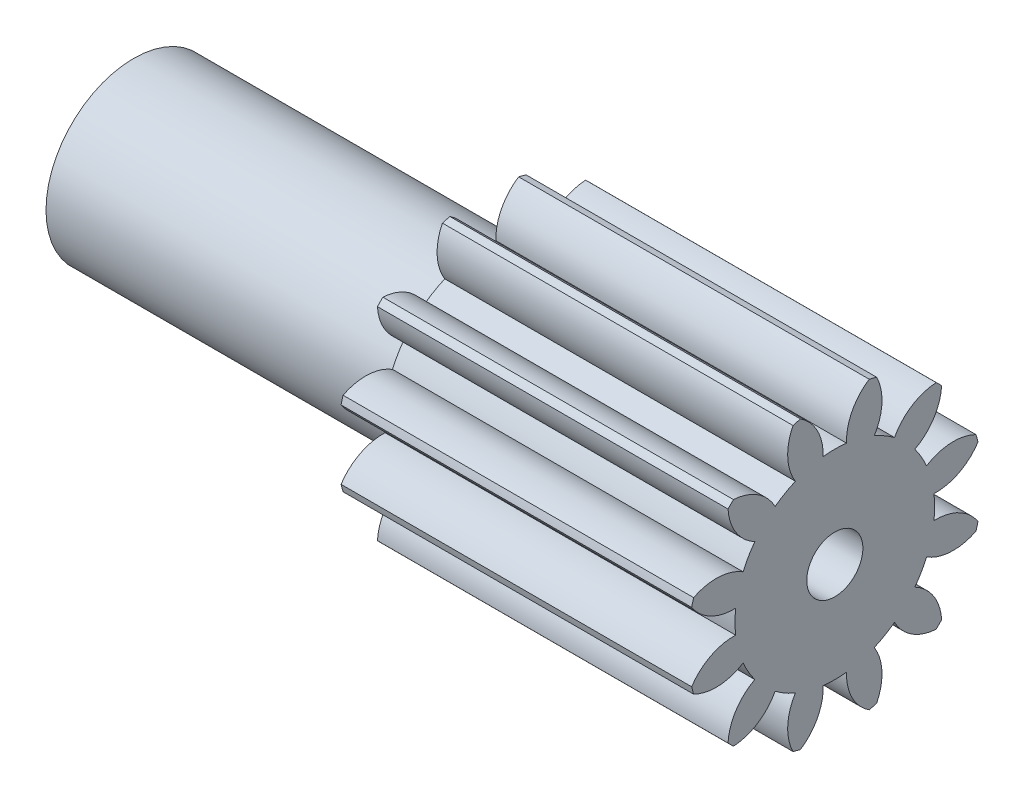
from build123d import *

# Parameters (mm, degrees)
BASPROSKE_W      = 5
BASPROSKE_H      = 2.1
TOOTHCUT_DEPTH   = 6.815496539
TEETHCUTS_COUNT  = 12
TEETHCUTS_ANGLE  = 330
HUBNEAONESKE_R   = 1.25
HUBNEARONE_DEPTH = 5.0000508
BORSKE_R         = 0.4
BORE_DEPTH       = 10.0000508


with BuildPart() as part:
    # BasProSke → Base-Revolve (revolve)
    with BuildSketch(Plane(origin=(0, 0, 0), x_dir=(1, 0, 0), z_dir=(0, 1, 0)), mode=Mode.PRIVATE) as base_revolve_sk:
        with Locations((2.5, 1.05)):
            Rectangle(BASPROSKE_W, BASPROSKE_H)
    revolve(base_revolve_sk.sketch.rotate(Axis((-10, 0, 0), (1, 0, 0)), 180), axis=Axis((-10, 0, 0), (1, 0, 0)))

    # TooCutSke → ToothCut (cut, through all)
    with BuildSketch(Plane(origin=(0, 0, 0), x_dir=(0, 0, -1), z_dir=(1, 0, 0))):
        with BuildLine():
            ThreePointArc((0.16674814, 1.41420333), (0, 1.424), (-0.16674814, 1.41420333))
            ThreePointArc((-0.16674814, 1.41420333), (-0.254548019, 1.786124318), (-0.520302512, 2.060730564))
            ThreePointArc((-0.520302512, 2.060730564), (0, 2.1254), (0.520302512, 2.060730564))
            ThreePointArc((0.520302512, 2.060730564), (0.254548019, 1.786124318), (0.16674814, 1.41420333))
        make_face()
    toothcut = extrude(amount=TOOTHCUT_DEPTH, mode=Mode.SUBTRACT)

    # TeethCuts: ToothCut ×12 about axis
    teethcuts_axis = Axis((-10, 0, 0), (1, 0, 0))
    for i in range(1, TEETHCUTS_COUNT):
        add(toothcut.rotate(teethcuts_axis, i * TEETHCUTS_ANGLE / (TEETHCUTS_COUNT - 1)), mode=Mode.SUBTRACT)

    # HubNeaOneSke → HubNearOne (add)
    with BuildSketch(Plane.ZY):
        with Locations(Location((0, 0, 0), (0, 0, 180))):
            Circle(HUBNEAONESKE_R)
    extrude(amount=HUBNEARONE_DEPTH)

    # BorSke → Bore (cut, symmetric)
    with BuildSketch(Plane(origin=(0, 0, 0), x_dir=(0, 0, -1), z_dir=(1, 0, 0))):
        with Locations(Location((0, 0, 0), (0, 0, 180))):
            Circle(BORSKE_R)
    extrude(amount=BORE_DEPTH, both=True, mode=Mode.SUBTRACT)


solid = part.part
